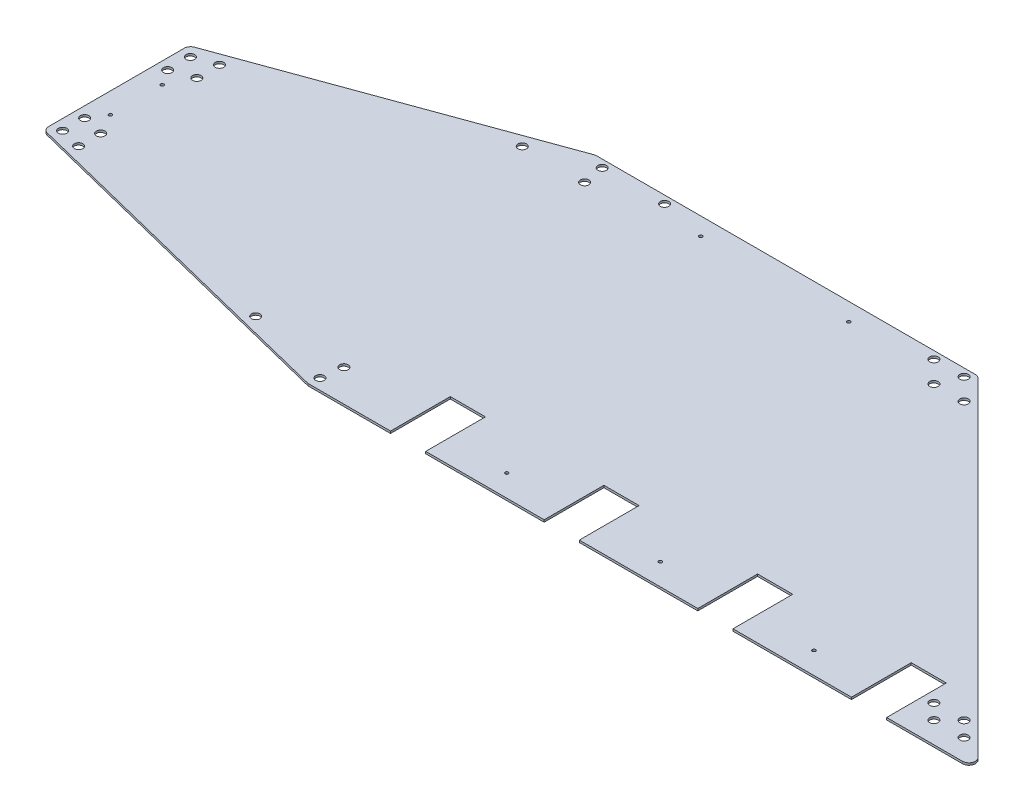
from build123d import *

# Parameters (mm, degrees)
SKETCH2_R           = 6.35
SKETCH2_R_2         = 2.45745
BOSS_EXTRUDE1_DEPTH = 3.175


with BuildPart() as part:
    # Sketch2 → Boss-Extrude1 (new body)
    with BuildSketch(Plane(origin=(0, 0, 0), x_dir=(1, 0, 0), z_dir=(0, 1, 0))):
        with BuildLine():
            ThreePointArc((-523.9004, 138.064786013), (-521.881202428, 132.200610461), (-516.679706056, 128.82271922))
            Line((-516.679706056, 128.82271922), (-1.134783113, 0.282933207))
            ThreePointArc((-1.134783113, 0.282933207), (0.008717447, 0.070997906), (1.169522943, 0))
            Line((1.169522943, 0), (122.844814136, 0))
            Line((122.844814136, 0), (122.844814136, 88.9))
            Line((122.844814136, 88.9), (175.168814136, 88.9))
            Line((175.168814136, 88.9), (175.168814136, 0))
            Line((175.168814136, 0), (351.444814136, 0))
            Line((351.444814136, 0), (351.444814136, 88.9))
            Line((351.444814136, 88.9), (403.768814136, 88.9))
            Line((403.768814136, 88.9), (403.768814136, 0))
            Line((403.768814136, 0), (580.044814136, 0))
            Line((580.044814136, 0), (580.044814136, 88.9))
            Line((580.044814136, 88.9), (632.368814136, 88.9))
            Line((632.368814136, 88.9), (632.368814136, 0))
            Line((632.368814136, 0), (808.644814136, 0))
            Line((808.644814136, 0), (808.644814136, 88.9))
            Line((808.644814136, 88.9), (860.968814136, 88.9))
            Line((860.968814136, 88.9), (860.968814136, 0))
            Line((860.968814136, 0), (973.929215818, 0))
            ThreePointArc((973.929215818, 0), (982.729168366, 5.879940307), (980.664407909, 16.260192091))
            Line((980.664407909, 16.260192091), (491.714407909, 505.210192091))
            ThreePointArc((491.714407909, 505.210192091), (488.624275512, 507.274952547), (484.979215818, 508))
            Line((484.979215818, 508), (-78.566585303, 508))
            ThreePointArc((-78.566585303, 508), (-80.220584195, 507.855293847), (-81.824327168, 507.425572213))
            Line((-81.824327168, 507.425572213), (-517.633141865, 348.804135832))
            ThreePointArc((-517.633141865, 348.804135832), (-522.177823222, 345.316879176), (-523.9004, 339.853563619))
            Line((-523.9004, 339.853563619), (-523.9004, 138.064786013))
        make_face()
        with Locations((1.976178059, 15.875)):
            Circle(SKETCH2_R, mode=Mode.SUBTRACT)
        with Locations((-125.36611658, 47.625)):
            Circle(SKETCH2_R, mode=Mode.SUBTRACT)
        with Locations((5.874587868, 47.625)):
            Circle(SKETCH2_R, mode=Mode.SUBTRACT)
        with Locations((-476.2754, 135.116510814)):
            Circle(SKETCH2_R, mode=Mode.SUBTRACT)
        with Locations((-508.0254, 143.032674904)):
            Circle(SKETCH2_R, mode=Mode.SUBTRACT)
        with Locations((-476.2754, 167.838493546)):
            Circle(SKETCH2_R, mode=Mode.SUBTRACT)
        with Locations((-508.0254, 175.754657636)):
            Circle(SKETCH2_R, mode=Mode.SUBTRACT)
        with Locations((-493.0394, 199.090929312)):
            Circle(SKETCH2_R_2, mode=Mode.SUBTRACT)
        with Locations((263.306814136, 32.385)):
            Circle(SKETCH2_R_2, mode=Mode.SUBTRACT)
        with Locations((491.906814136, 32.385)):
            Circle(SKETCH2_R_2, mode=Mode.SUBTRACT)
        with Locations((720.506814136, 32.385)):
            Circle(SKETCH2_R_2, mode=Mode.SUBTRACT)
        with Locations((877.339781319, 53.975)):
            Circle(SKETCH2_R, mode=Mode.SUBTRACT)
        with Locations((899.564781319, 31.75)):
            Circle(SKETCH2_R, mode=Mode.SUBTRACT)
        with Locations((944.466061924, 31.75)):
            Circle(SKETCH2_R, mode=Mode.SUBTRACT)
        with Locations((922.241061924, 53.975)):
            Circle(SKETCH2_R, mode=Mode.SUBTRACT)
        with Locations((-493.0394, 276.290731215)):
            Circle(SKETCH2_R_2, mode=Mode.SUBTRACT)
        with Locations((-508.0254, 299.333610137)):
            Circle(SKETCH2_R, mode=Mode.SUBTRACT)
        with Locations((-476.2754, 310.889665075)):
            Circle(SKETCH2_R, mode=Mode.SUBTRACT)
        with Locations((-508.0254, 333.121254413)):
            Circle(SKETCH2_R, mode=Mode.SUBTRACT)
        with Locations((-476.2754, 344.677309351)):
            Circle(SKETCH2_R, mode=Mode.SUBTRACT)
        with Locations((-146.038641871, 464.873096997)):
            Circle(SKETCH2_R, mode=Mode.SUBTRACT)
        with Locations((-53.207852166, 464.873081124)):
            Circle(SKETCH2_R, mode=Mode.SUBTRACT)
        with Locations((-58.806228375, 496.623082082)):
            Circle(SKETCH2_R, mode=Mode.SUBTRACT)
        with Locations((34.024561331, 496.623066209)):
            Circle(SKETCH2_R, mode=Mode.SUBTRACT)
        with Locations((102.750499745, 481.637016811)):
            Circle(SKETCH2_R_2, mode=Mode.SUBTRACT)
        with Locations((322.928740552, 481.637016811)):
            Circle(SKETCH2_R_2, mode=Mode.SUBTRACT)
        with Locations((466.441944838, 464.872992272)):
            Circle(SKETCH2_R, mode=Mode.SUBTRACT)
        with Locations((511.343225443, 464.872984595)):
            Circle(SKETCH2_R, mode=Mode.SUBTRACT)
        with Locations((434.691950267, 496.622997701)):
            Circle(SKETCH2_R, mode=Mode.SUBTRACT)
        with Locations((479.593230872, 496.622990024)):
            Circle(SKETCH2_R, mode=Mode.SUBTRACT)
    extrude(amount=BOSS_EXTRUDE1_DEPTH)


solid = part.part
